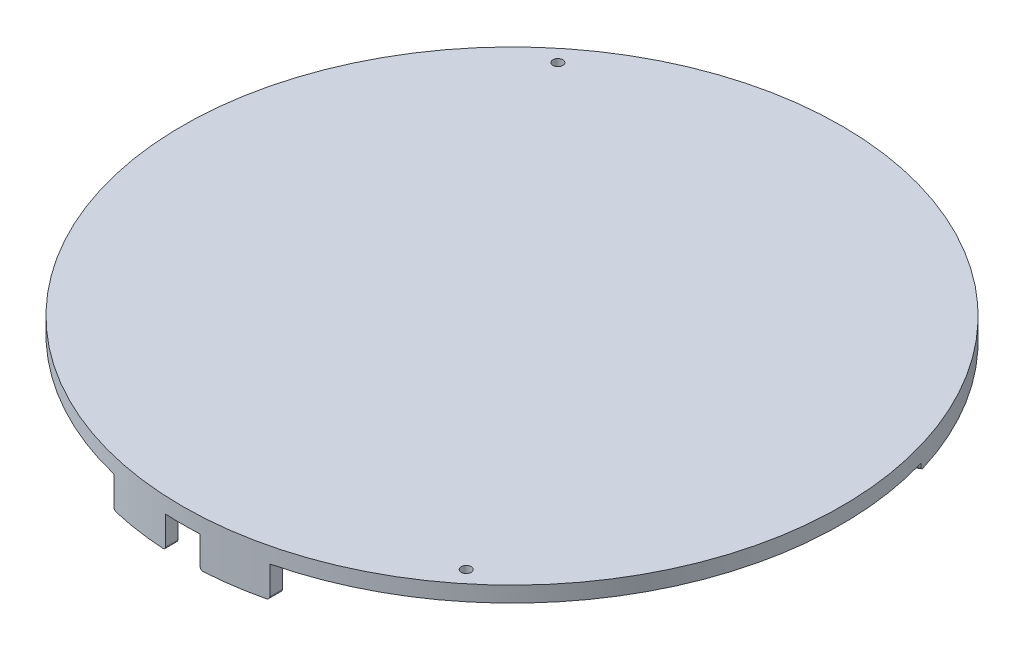
from build123d import *
from build123d.topology import SkipClean

# Parameters (mm, degrees)
SKETCH1_R          = 105.6
EXTRUDE1_DEPTH     = 5
SKETCH2_R          = 1.5875
CUT_EXTRUDE1_DEPTH = 6
EXTRUDE2_DEPTH     = 10
CIRPATTERN1_COUNT  = 3
EXTRUDE3_DEPTH     = 10
EXTRUDE4_DEPTH     = 8
FILLET1_R          = 1


with BuildPart() as part:
    # Sketch1 → Extrude1 (new body)
    with BuildSketch(Plane(origin=(0, 0, 0), x_dir=(1, 0, 0), z_dir=(0, 1, 0))):
        with Locations(Location((0, 0, 0), (0, 0, 270))):  # turned: the seam where the file's is
            Circle(SKETCH1_R)
    extrude(amount=EXTRUDE1_DEPTH)

    # Sketch2 → Cut-Extrude1 (cut, through all)
    with BuildSketch(Plane(origin=(0, 5, 0), x_dir=(1, 0, 0), z_dir=(0, 1, 0))):
        with Locations(Location((-62.980195842, 77.675574872, 0), (0, 0, 270))):  # turned: the seam where the file's is
            Circle(SKETCH2_R)
        with Locations(Location((62.980195842, -77.675574872, 0), (0, 0, 270))):  # turned: the seam where the file's is
            Circle(SKETCH2_R)
    extrude(amount=-CUT_EXTRUDE1_DEPTH, mode=Mode.SUBTRACT)

    # Sketch3 → Extrude2 (add)
    with BuildSketch(Plane.XZ):
        with BuildLine():
            Line((-25, 102.598050664), (-25, 98.579358894))
            ThreePointArc((-25, 98.579358894), (0, 101.7), (25, 98.579358894))
            Line((25, 98.579358894), (25, 102.598050664))
            ThreePointArc((25, 102.598050664), (0, 105.6), (-25, 102.598050664))
        make_face()
    extrude2 = extrude(amount=EXTRUDE2_DEPTH)

    # CirPattern1: Extrude2 ×3 about axis
    with SkipClean():  # keep this step's faces unmerged: merging them makes the solid invalid here
        cirpattern1_axis = Axis((0, 0, 0), (0, 1, 0))
        for i in range(1, CIRPATTERN1_COUNT):
            add(extrude2.rotate(cirpattern1_axis, i * 360 / CIRPATTERN1_COUNT))

    # Sketch4 → Extrude3 (cut)
    with SkipClean():  # keep this step's faces unmerged: merging them makes the solid invalid here
        with BuildSketch(Plane.XZ.offset(10)):
            with BuildLine():
                Line((5.5, 105.456673568), (5.5, 101.551169368))
                ThreePointArc((5.5, 101.551169368), (0, 101.7), (-5.5, 101.551169368))
                Line((-5.5, 101.551169368), (-5.5, 105.456673568))
                ThreePointArc((-5.5, 105.456673568), (0, 105.6), (5.5, 105.456673568))
            make_face()
        extrude(amount=-EXTRUDE3_DEPTH, mode=Mode.SUBTRACT)

    # Sketch5 → Extrude4 (cut)
    with SkipClean():  # keep this step's faces unmerged: merging them makes the solid invalid here
        with BuildSketch(Plane.XZ.offset(10)):
            with BuildLine():
                Line((72.872229091, -70.940314542), (76.352518254, -72.949660426))
                ThreePointArc((76.352518254, -72.949660426), (91.45228264, -52.8), (101.352518254, -29.648390237))
                Line((101.352518254, -29.648390237), (97.872229091, -27.639044353))
                ThreePointArc((97.872229091, -27.639044353), (88.074783565, -50.85), (72.872229091, -70.940314542))
            make_face()
            with BuildLine():
                Line((-76.352518254, -72.949660426), (-72.872229091, -70.940314542))
                ThreePointArc((-72.872229091, -70.940314542), (-88.074783565, -50.85), (-97.872229091, -27.639044353))
                Line((-97.872229091, -27.639044353), (-101.352518254, -29.648390237))
                ThreePointArc((-101.352518254, -29.648390237), (-91.45228264, -52.8), (-76.352518254, -72.949660426))
            make_face()
        extrude(amount=-EXTRUDE4_DEPTH, mode=Mode.SUBTRACT)

    # Fillet1
    fillet1_edges = [part.edges().sort_by_distance(p)[0] for p in [
        (25, -10, 100.588704779),
        (5.5, -10, 103.503921468),
        (-5.5, -10, 103.503921468),
        (-25, -10, 100.588704779),
        (99.612373672, -2, -28.643717295),
        (74.612373672, -2, -71.944987484),
        (-74.612373672, -2, -71.944987484),
        (-99.612373672, -2, -28.643717295),
    ]]
    fillet(fillet1_edges, radius=FILLET1_R)


solid = part.part
